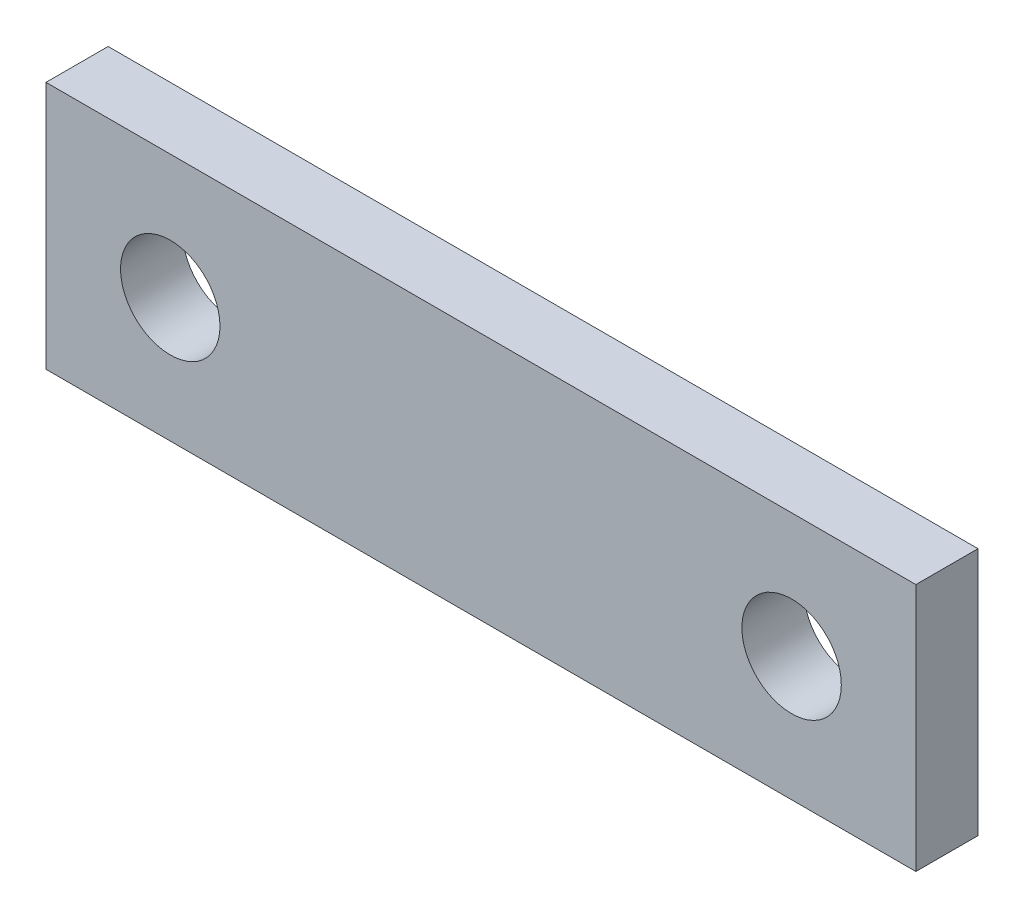
from build123d import *

# Parameters (mm, degrees)
SKETCH_1_R      = 4
EXTRUDE_1_DEPTH = 5


with BuildPart() as part:
    # 草图1 → 凸台-拉伸1 (new body)
    with BuildSketch(Plane.XY):
        Polygon((10, -10), (40, -10), (60, -10), (60, 10), (40, 10), (10, 10), (-10, 10), (-10, -10), align=None)
        Circle(SKETCH_1_R, mode=Mode.SUBTRACT)
        with Locations((50, 0)):
            Circle(SKETCH_1_R, mode=Mode.SUBTRACT)
    extrude(amount=EXTRUDE_1_DEPTH)


solid = part.part
